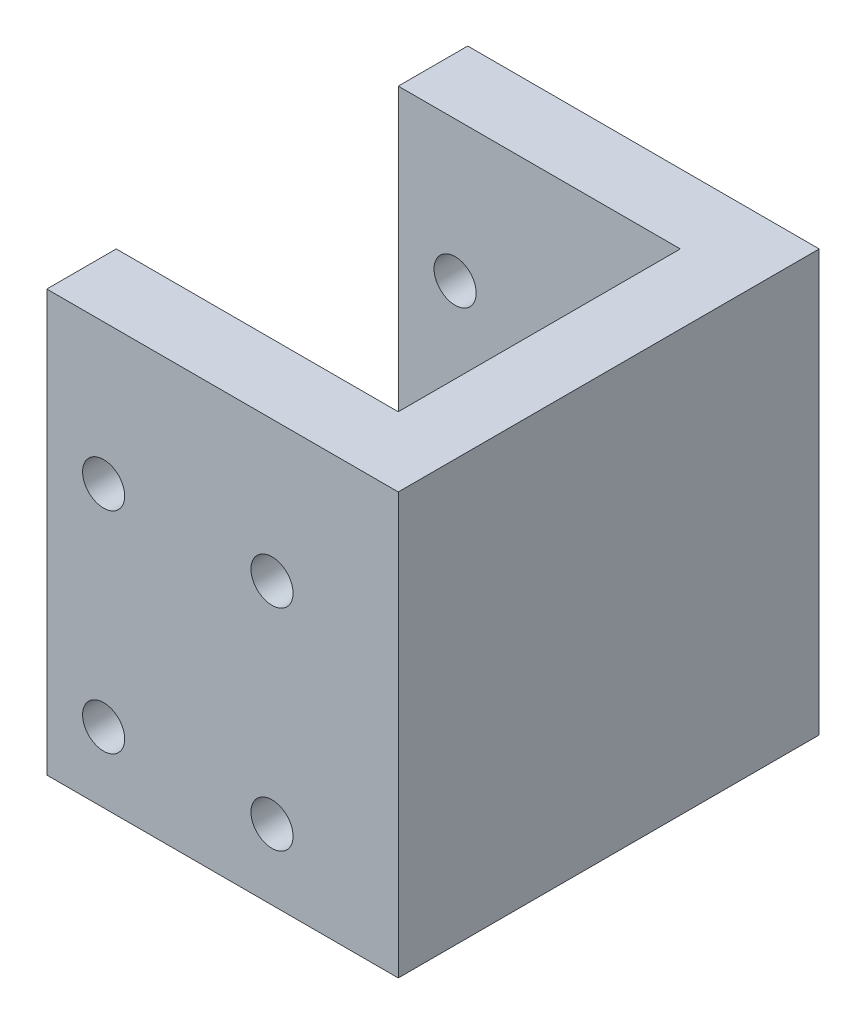
from build123d import *

# Parameters (mm, degrees)
EXTRUDE1_DEPTH     = 30
SKETCH3_R          = 1.5
CUT_EXTRUDE1_DEPTH = 30


with BuildPart() as part:
    # Sketch2 → Extrude1 (new body)
    with BuildSketch(Plane.XZ.offset(470)):
        Polygon((-380.315803698, -350.2), (-400.415803698, -350.2), (-400.415803698, -355.15), (-380.315803698, -355.15), (-380.315803698, -375.25), (-400.415803698, -375.25), (-400.415803698, -380.2), (-380.315803698, -380.2), (-375.365803698, -380.2), (-375.365803698, -350.2), align=None)
    extrude(amount=-EXTRUDE1_DEPTH)

    # Sketch3 → Cut-Extrude1 (cut)
    with BuildSketch(Plane.XY.offset(-350.2)):
        with Locations((-384.365803698, -465)):
            Circle(SKETCH3_R)
        with Locations((-396.365803698, -465)):
            Circle(SKETCH3_R)
        with Locations((-384.365803698, -450)):
            Circle(SKETCH3_R)
        with Locations((-396.365803698, -450)):
            Circle(SKETCH3_R)
    extrude(amount=-CUT_EXTRUDE1_DEPTH, mode=Mode.SUBTRACT)


solid = part.part
